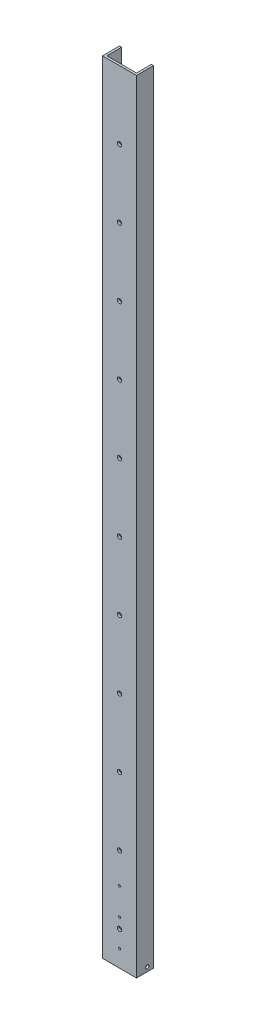
from build123d import *

# Parameters (mm, degrees)
BOSS_EXTRUDE1_DEPTH = 1168.4
CUT_EXTRUDE1_REACH  = 27.4
SKETCH2_R           = 3.175
CUT_EXTRUDE2_REACH  = 5.175
SKETCH3_R           = 1.5875
SKETCH4_R           = 2.667
CUT_EXTRUDE3_DEPTH  = 51.8


with BuildPart() as part:
    # Sketch1 → Boss-Extrude1 (new body)
    with BuildSketch(Plane(origin=(0, 0, 0), x_dir=(1, 0, 0), z_dir=(0, 1, 0))):
        Polygon((3.175, 3.175), (3.175, 25.4), (0, 25.4), (0, 0), (50.8, 0), (50.8, 25.4), (47.625, 25.4), (47.625, 3.175), align=None)
    extrude(amount=BOSS_EXTRUDE1_DEPTH)

    # Sketch2 → Cut-Extrude1 (cut, up to next)
    with BuildSketch(Plane.XY, mode=Mode.PRIVATE) as cut_extrude1_sk1:
        with Locations((25.4, 50.8)):
            Circle(SKETCH2_R)
    cut_extrude1_tool1 = extrude(cut_extrude1_sk1.sketch, amount=-CUT_EXTRUDE1_REACH, mode=Mode.PRIVATE) & part.part
    add(cut_extrude1_tool1.solids().sort_by_distance((25.4, 50.8, 0))[0], mode=Mode.SUBTRACT)
    # Sketch2 → Cut-Extrude1 (cut, up to next)
    with BuildSketch(Plane.XY, mode=Mode.PRIVATE) as cut_extrude1_sk2:
        with Locations((25.4, 152.4)):
            Circle(SKETCH2_R)
    cut_extrude1_tool2 = extrude(cut_extrude1_sk2.sketch, amount=-CUT_EXTRUDE1_REACH, mode=Mode.PRIVATE) & part.part
    add(cut_extrude1_tool2.solids().sort_by_distance((25.4, 152.4, 0))[0], mode=Mode.SUBTRACT)
    # Sketch2 → Cut-Extrude1 (cut, up to next)
    with BuildSketch(Plane.XY, mode=Mode.PRIVATE) as cut_extrude1_sk3:
        with Locations((25.4, 254)):
            Circle(SKETCH2_R)
    cut_extrude1_tool3 = extrude(cut_extrude1_sk3.sketch, amount=-CUT_EXTRUDE1_REACH, mode=Mode.PRIVATE) & part.part
    add(cut_extrude1_tool3.solids().sort_by_distance((25.4, 254, 0))[0], mode=Mode.SUBTRACT)
    # Sketch2 → Cut-Extrude1 (cut, up to next)
    with BuildSketch(Plane.XY, mode=Mode.PRIVATE) as cut_extrude1_sk4:
        with Locations((25.4, 355.6)):
            Circle(SKETCH2_R)
    cut_extrude1_tool4 = extrude(cut_extrude1_sk4.sketch, amount=-CUT_EXTRUDE1_REACH, mode=Mode.PRIVATE) & part.part
    add(cut_extrude1_tool4.solids().sort_by_distance((25.4, 355.6, 0))[0], mode=Mode.SUBTRACT)
    # Sketch2 → Cut-Extrude1 (cut, up to next)
    with BuildSketch(Plane.XY, mode=Mode.PRIVATE) as cut_extrude1_sk5:
        with Locations((25.4, 457.2)):
            Circle(SKETCH2_R)
    cut_extrude1_tool5 = extrude(cut_extrude1_sk5.sketch, amount=-CUT_EXTRUDE1_REACH, mode=Mode.PRIVATE) & part.part
    add(cut_extrude1_tool5.solids().sort_by_distance((25.4, 457.2, 0))[0], mode=Mode.SUBTRACT)
    # Sketch2 → Cut-Extrude1 (cut, up to next)
    with BuildSketch(Plane.XY, mode=Mode.PRIVATE) as cut_extrude1_sk6:
        with Locations((25.4, 558.8)):
            Circle(SKETCH2_R)
    cut_extrude1_tool6 = extrude(cut_extrude1_sk6.sketch, amount=-CUT_EXTRUDE1_REACH, mode=Mode.PRIVATE) & part.part
    add(cut_extrude1_tool6.solids().sort_by_distance((25.4, 558.8, 0))[0], mode=Mode.SUBTRACT)
    # Sketch2 → Cut-Extrude1 (cut, up to next)
    with BuildSketch(Plane.XY, mode=Mode.PRIVATE) as cut_extrude1_sk7:
        with Locations((25.4, 660.4)):
            Circle(SKETCH2_R)
    cut_extrude1_tool7 = extrude(cut_extrude1_sk7.sketch, amount=-CUT_EXTRUDE1_REACH, mode=Mode.PRIVATE) & part.part
    add(cut_extrude1_tool7.solids().sort_by_distance((25.4, 660.4, 0))[0], mode=Mode.SUBTRACT)
    # Sketch2 → Cut-Extrude1 (cut, up to next)
    with BuildSketch(Plane.XY, mode=Mode.PRIVATE) as cut_extrude1_sk8:
        with Locations((25.4, 762)):
            Circle(SKETCH2_R)
    cut_extrude1_tool8 = extrude(cut_extrude1_sk8.sketch, amount=-CUT_EXTRUDE1_REACH, mode=Mode.PRIVATE) & part.part
    add(cut_extrude1_tool8.solids().sort_by_distance((25.4, 762, 0))[0], mode=Mode.SUBTRACT)
    # Sketch2 → Cut-Extrude1 (cut, up to next)
    with BuildSketch(Plane.XY, mode=Mode.PRIVATE) as cut_extrude1_sk9:
        with Locations((25.4, 863.6)):
            Circle(SKETCH2_R)
    cut_extrude1_tool9 = extrude(cut_extrude1_sk9.sketch, amount=-CUT_EXTRUDE1_REACH, mode=Mode.PRIVATE) & part.part
    add(cut_extrude1_tool9.solids().sort_by_distance((25.4, 863.6, 0))[0], mode=Mode.SUBTRACT)
    # Sketch2 → Cut-Extrude1 (cut, up to next)
    with BuildSketch(Plane.XY, mode=Mode.PRIVATE) as cut_extrude1_sk10:
        with Locations((25.4, 965.2)):
            Circle(SKETCH2_R)
    cut_extrude1_tool10 = extrude(cut_extrude1_sk10.sketch, amount=-CUT_EXTRUDE1_REACH, mode=Mode.PRIVATE) & part.part
    add(cut_extrude1_tool10.solids().sort_by_distance((25.4, 965.2, 0))[0], mode=Mode.SUBTRACT)
    # Sketch2 → Cut-Extrude1 (cut, up to next)
    with BuildSketch(Plane.XY, mode=Mode.PRIVATE) as cut_extrude1_sk11:
        with Locations((25.4, 1066.8)):
            Circle(SKETCH2_R)
    cut_extrude1_tool11 = extrude(cut_extrude1_sk11.sketch, amount=-CUT_EXTRUDE1_REACH, mode=Mode.PRIVATE) & part.part
    add(cut_extrude1_tool11.solids().sort_by_distance((25.4, 1066.8, 0))[0], mode=Mode.SUBTRACT)

    # Sketch3 → Cut-Extrude2 (cut, up to next)
    with BuildSketch(Plane(origin=(0, 0, -3.175), x_dir=(-1, 0, 0), z_dir=(0, 0, -1)), mode=Mode.PRIVATE) as cut_extrude2_sk1:
        with Locations((-25.4, 25.4)):
            Circle(SKETCH3_R)
    cut_extrude2_tool1 = extrude(cut_extrude2_sk1.sketch, amount=-CUT_EXTRUDE2_REACH, mode=Mode.PRIVATE) & part.part
    add(cut_extrude2_tool1.solids().sort_by_distance((25.4, 25.4, -3.175))[0], mode=Mode.SUBTRACT)
    # Sketch3 → Cut-Extrude2 (cut, up to next)
    with BuildSketch(Plane(origin=(0, 0, -3.175), x_dir=(-1, 0, 0), z_dir=(0, 0, -1)), mode=Mode.PRIVATE) as cut_extrude2_sk2:
        with Locations((-25.4, 66.020295879)):
            Circle(SKETCH3_R)
    cut_extrude2_tool2 = extrude(cut_extrude2_sk2.sketch, amount=-CUT_EXTRUDE2_REACH, mode=Mode.PRIVATE) & part.part
    add(cut_extrude2_tool2.solids().sort_by_distance((25.4, 66.020296, -3.175))[0], mode=Mode.SUBTRACT)
    # Sketch3 → Cut-Extrude2 (cut, up to next)
    with BuildSketch(Plane(origin=(0, 0, -3.175), x_dir=(-1, 0, 0), z_dir=(0, 0, -1)), mode=Mode.PRIVATE) as cut_extrude2_sk3:
        with Locations((-25.4, 106.640591758)):
            Circle(SKETCH3_R)
    cut_extrude2_tool3 = extrude(cut_extrude2_sk3.sketch, amount=-CUT_EXTRUDE2_REACH, mode=Mode.PRIVATE) & part.part
    add(cut_extrude2_tool3.solids().sort_by_distance((25.4, 106.640592, -3.175))[0], mode=Mode.SUBTRACT)

    # Sketch4 → Cut-Extrude3 (cut, through all)
    with BuildSketch(Plane.ZY):
        with Locations((-15.875, 6.35)):
            Circle(SKETCH4_R)
    extrude(amount=-CUT_EXTRUDE3_DEPTH, mode=Mode.SUBTRACT)


solid = part.part
